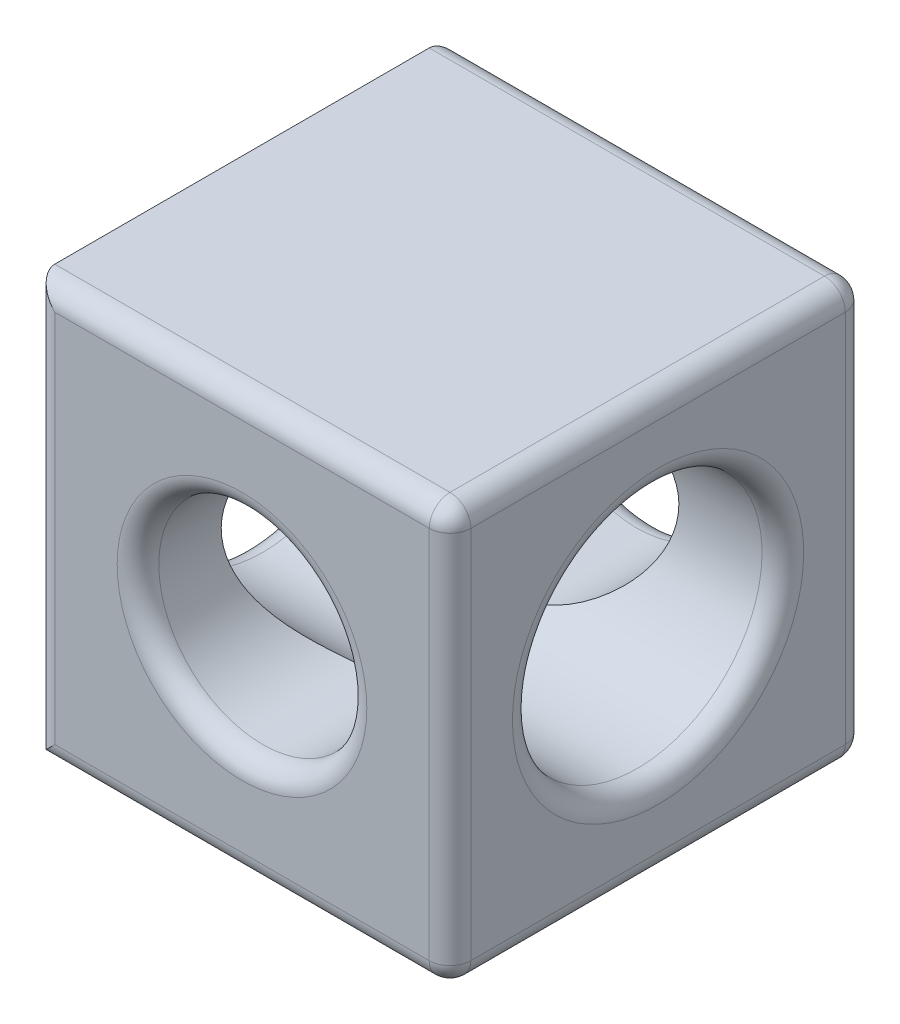
from build123d import *

# Parameters (mm, degrees)
SKETCH_1_W          = 10
SKETCH_1_H          = 10
EXTRUDE_1_DEPTH     = 10
SKETCH_4_R          = 3
CUT_EXTRUDE_2_DEPTH = 11
SKETCH_5_R          = 2.5
CUT_EXTRUDE_3_DEPTH = 11
FILLET_1_R          = 0.5


with BuildPart() as part:
    # 草图1 → 凸台-拉伸1 (new body)
    with BuildSketch(Plane.XY):
        with Locations((5, 5)):
            Rectangle(SKETCH_1_W, SKETCH_1_H)
    extrude(amount=EXTRUDE_1_DEPTH)

    # 草图4 → 切除-拉伸2 (cut, through all)
    with BuildSketch(Plane(origin=(10, 0, 0), x_dir=(0, 0, -1), z_dir=(1, 0, 0))):
        with Locations((-5, 5)):
            Circle(SKETCH_4_R)
    extrude(amount=-CUT_EXTRUDE_2_DEPTH, mode=Mode.SUBTRACT)

    # 草图5 → 切除-拉伸3 (cut, through all)
    with BuildSketch(Plane.XY.offset(10)):
        with Locations((5, 5)):
            Circle(SKETCH_5_R)
    extrude(amount=-CUT_EXTRUDE_3_DEPTH, mode=Mode.SUBTRACT)

    # 圆角1
    fillet_1_edges = [part.edges().sort_by_distance(p)[0] for p in [
        (10, 5, 10),
        (0, 5, 8),
        (10, 5, 8),
        (5, 10, 10),
        (2.5, 5, 0),
        (2.5, 5, 10),
        (0, 5, 10),
        (5, 10, 0),
        (10, 5, 0),
        (5, 0, 0),
        (0, 5, 0),
        (10, 10, 5),
        (10, 0, 5),
        (5, 0, 10),
    ]]
    fillet(fillet_1_edges, radius=FILLET_1_R)


solid = part.part
